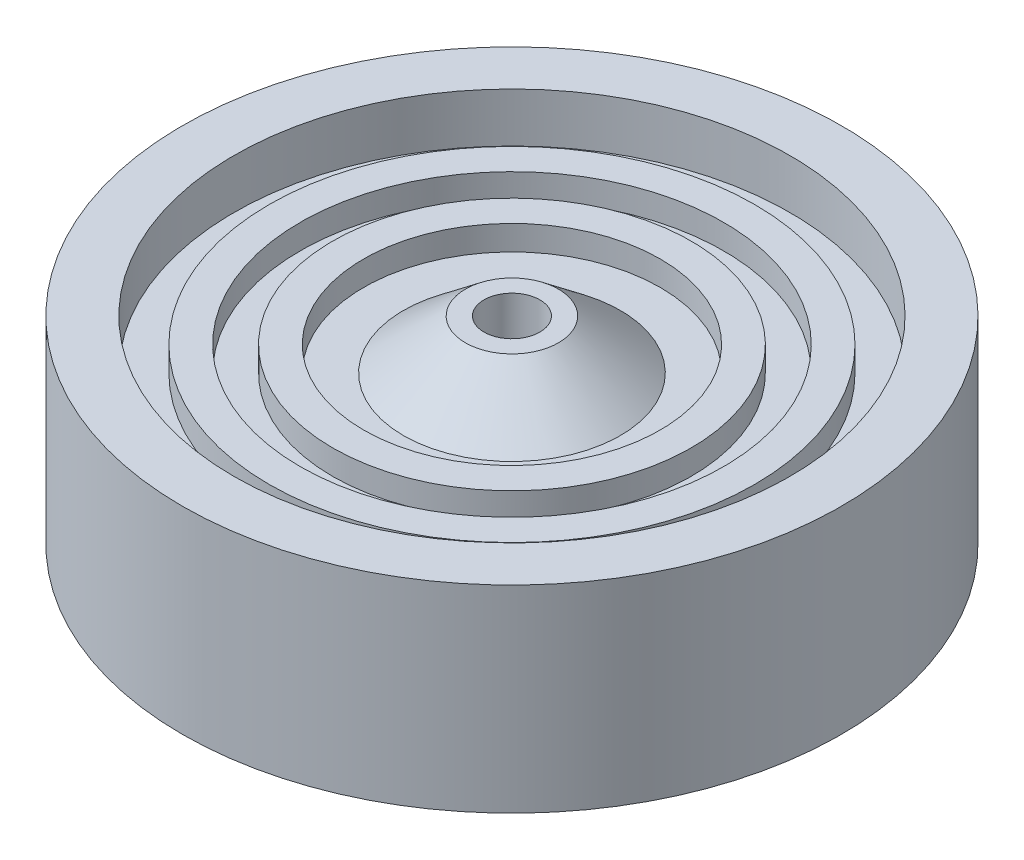
from build123d import *


with BuildPart() as part:
    # Sketch8 → Revolve3 (revolve)
    with BuildSketch(Plane.XY):
        Polygon((-62.270387008, 102.89349959), (-77.521457744, 90.728955074), (-87.325717502, 90.728955074), (-87.325717502, 96.811227332), (-94.945717502, 96.811227332), (-94.945717502, 90.728955074), (-102.934373602, 90.728955074), (-102.934373602, 96.811227332), (-110.554373602, 96.811227332), (-110.554373602, 90.728955074), (-119.269271165, 90.728955074), (-119.269271165, 102.89349959), (-131.969271165, 102.89349959), (-131.969271165, 54.235321529), (-119.269271165, 54.235321529), (-119.269271165, 66.399866044), (-110.554373602, 66.399866044), (-110.554373602, 60.317593787), (-102.934373602, 60.317593787), (-102.934373602, 66.399866044), (-94.945717502, 66.399866044), (-94.945717502, 60.317593787), (-87.325717502, 60.317593787), (-87.325717502, 66.399866044), (-77.521457744, 66.399866044), (-62.270387008, 54.235321529), (-57.695951482, 54.235321529), (-57.695951482, 102.89349959), align=None)
    revolve(axis=Axis((-50.811787608, 150.598792189, 0), (0, -1, 0)))


solid = part.part
